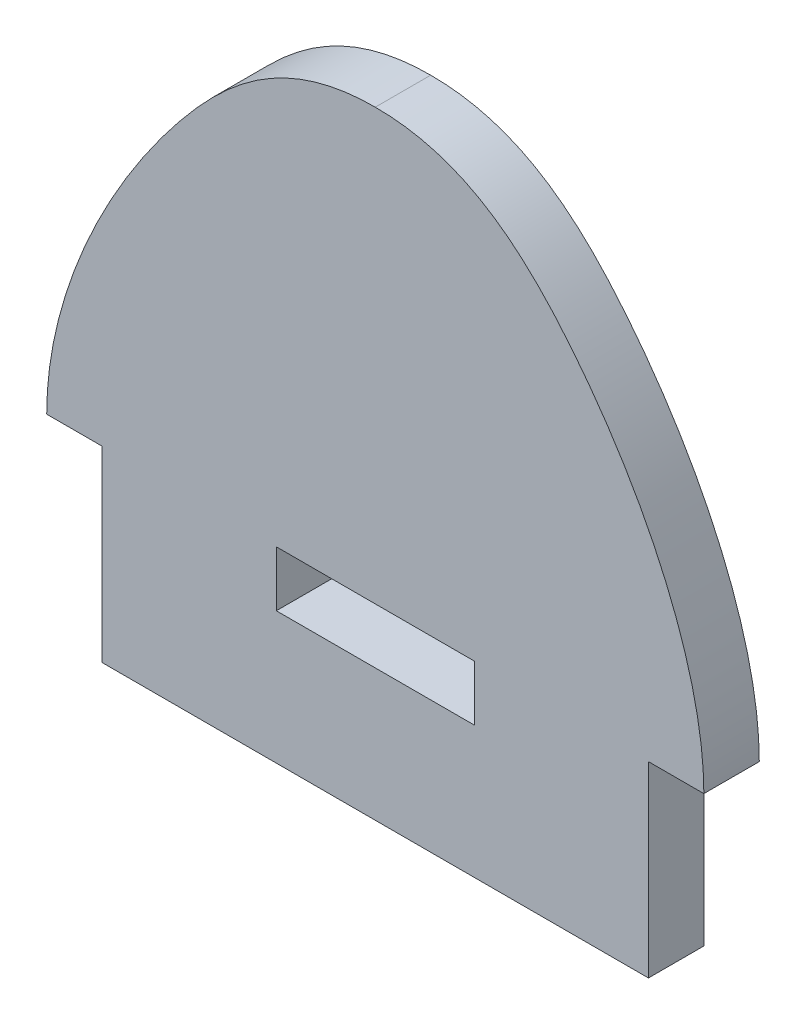
from build123d import *

# Parameters (mm, degrees)
SKETCH1_W           = 19.05
SKETCH1_H           = 5.334
BOSS_EXTRUDE1_DEPTH = 5.334


with BuildPart() as part:
    # Sketch1 → Boss-Extrude1 (new body)
    with BuildSketch(Plane.XY):
        with BuildLine():
            Line((52.578, 0), (57.912, 0))
            add(Edge.make_bspline(
                [(57.912, 0), (57.912, 10.018830831), (48.946545305, 29.285599761), (34.888394462, 41.402), (17.689605538, 41.402), (3.631454695, 29.285599761), (-5.334, 10.018830831), (-5.334, 0)],
                knots=[0, 0, 0, 0, 0.604390218, 1, 1, 1.395609782, 2, 2, 2, 2], degree=3))
            Line((-5.334, 0), (0, 0))
            Line((0, 0), (0, -18.034))
            Line((0, -18.034), (52.578, -18.034))
            Line((52.578, -18.034), (52.578, 0))
        make_face()
        with Locations((26.289, -2.667)):
            Rectangle(SKETCH1_W, SKETCH1_H, mode=Mode.SUBTRACT)
    extrude(amount=BOSS_EXTRUDE1_DEPTH)


solid = part.part
